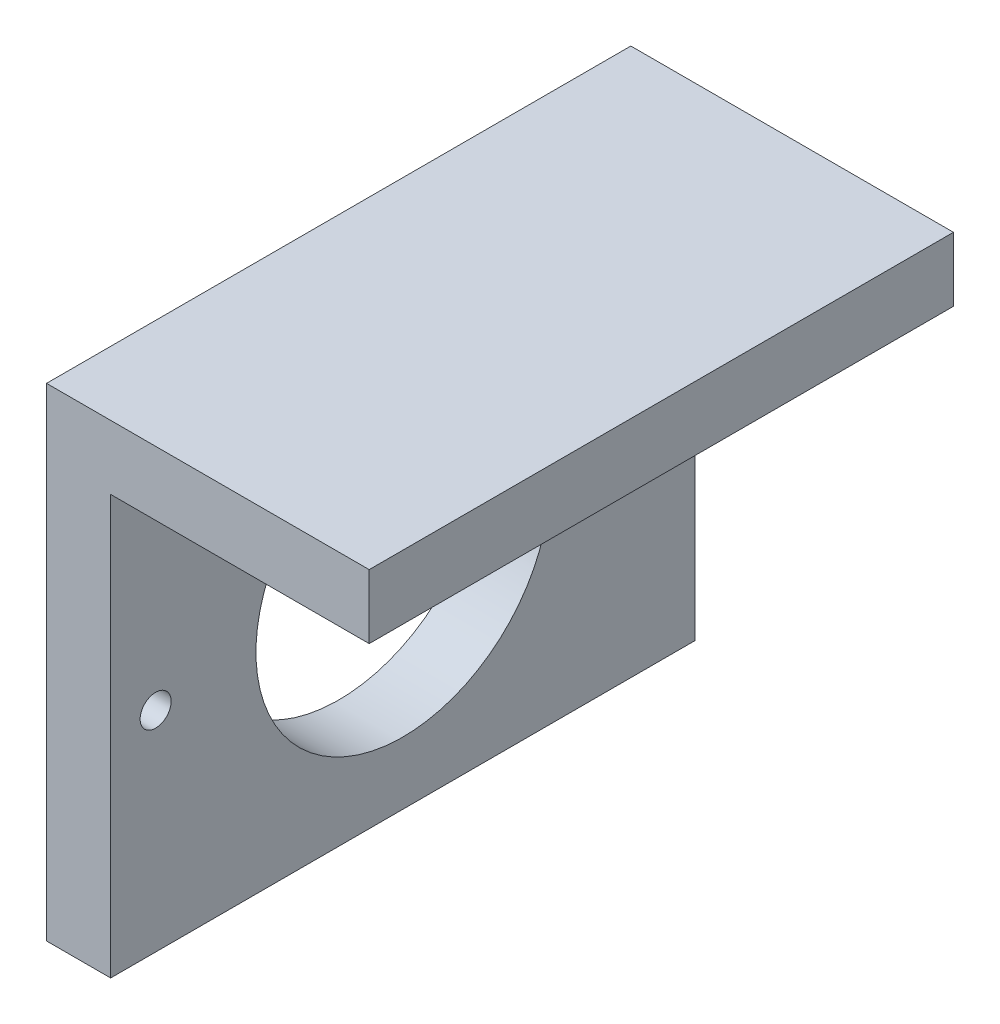
from build123d import *

# Parameters (mm, degrees)
SKETCH3_W           = 56.5
SKETCH3_H           = 46.7
SKETCH3_R           = 14.2
SKETCH3_R_2         = 1.5
BOSS_EXTRUDE1_DEPTH = 6.2
SKETCH4_W           = 56.5
SKETCH4_H           = 6.2
BOSS_EXTRUDE2_DEPTH = 25


with BuildPart() as part:
    # Sketch3 → Boss-Extrude1 (new body)
    with BuildSketch(Plane(origin=(0, 0, 0), x_dir=(0, 0, -1), z_dir=(1, 0, 0))):
        with Locations((28.25, 23.35)):
            Rectangle(SKETCH3_W, SKETCH3_H)
        with Locations((28.25, 20.25)):
            Circle(SKETCH3_R, mode=Mode.SUBTRACT)
        with Locations((4.35, 20.25)):
            Circle(SKETCH3_R_2, mode=Mode.SUBTRACT)
        with Locations((52.15, 20.25)):
            Circle(SKETCH3_R_2, mode=Mode.SUBTRACT)
    extrude(amount=BOSS_EXTRUDE1_DEPTH)

    # Sketch4 → Boss-Extrude2 (add)
    with BuildSketch(Plane(origin=(6.2, 0, 0), x_dir=(0, 0, -1), z_dir=(1, 0, 0))):
        with Locations((28.25, 43.6)):
            Rectangle(SKETCH4_W, SKETCH4_H)
    extrude(amount=BOSS_EXTRUDE2_DEPTH)


solid = part.part
